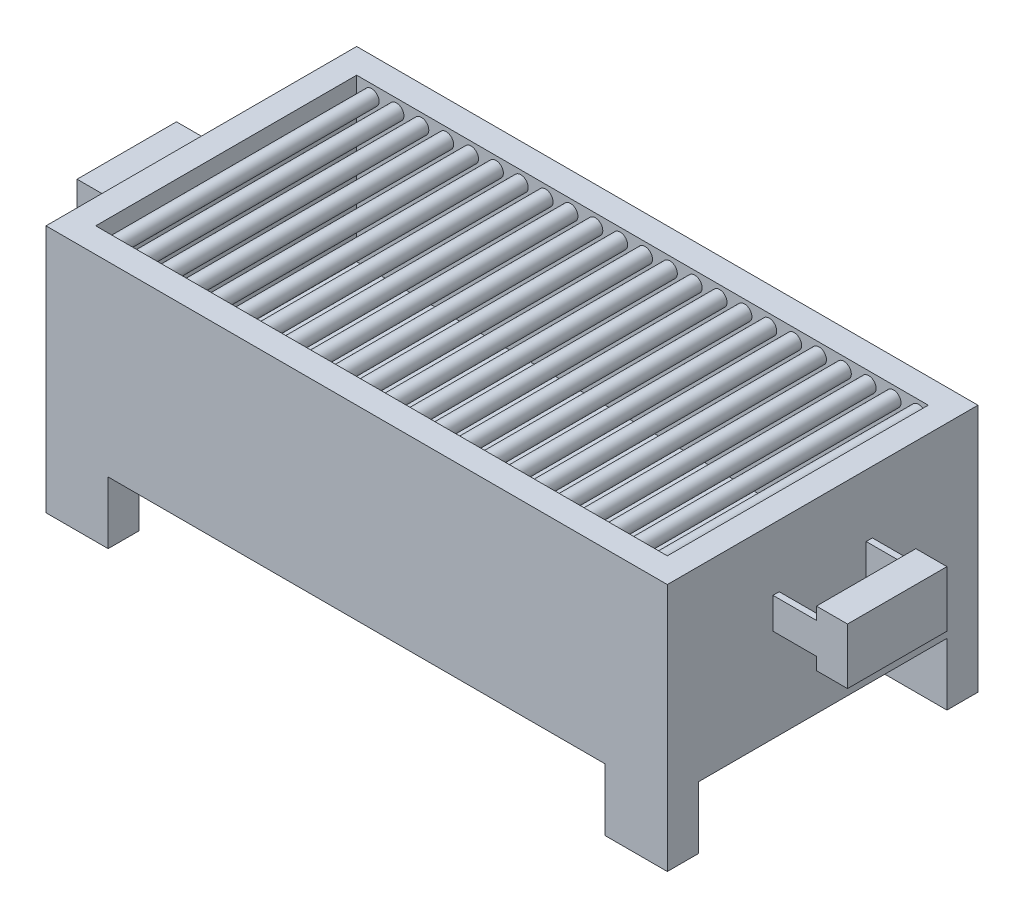
from build123d import *

# Parameters (mm, degrees)
SKETCH1_W           = 50
SKETCH1_H           = 20
BOSS_EXTRUDE1_DEPTH = 12.5
CUT_EXTRUDE1_START  = 20
SKETCH2_W           = 46
SKETCH2_H           = 21
CUT_EXTRUDE1_DEPTH  = 13
BOSS_EXTRUDE2_START = -10.5
SKETCH3_R           = 0.6
BOSS_EXTRUDE2_DEPTH = 21
SKETCH4_W           = 20
SKETCH4_H           = 5
CUT_EXTRUDE2_DEPTH  = 30
SKETCH5_W           = 40
SKETCH5_H           = 5
CUT_EXTRUDE3_DEPTH  = 20
BOSS_EXTRUDE3_DEPTH = 4
CUT_EXTRUDE4_START  = 15
SKETCH7_W           = 3
SKETCH7_H           = 7
CUT_EXTRUDE4_DEPTH  = 8


with BuildPart() as part:
    # Sketch1 → Boss-Extrude1 (new body, symmetric)
    with BuildSketch(Plane.XY):
        with Locations((0, 10)):
            Rectangle(SKETCH1_W, SKETCH1_H)
    extrude(amount=BOSS_EXTRUDE1_DEPTH, both=True)

    # Sketch2 → Cut-Extrude1 (cut)
    with BuildSketch(Plane(origin=(0, 0, 0), x_dir=(1, 0, 0), z_dir=(0, 1, 0)).offset(CUT_EXTRUDE1_START)):
        Rectangle(SKETCH2_W, SKETCH2_H)
    extrude(amount=-CUT_EXTRUDE1_DEPTH, mode=Mode.SUBTRACT)

    # Sketch3 → Boss-Extrude2 (add)
    with BuildSketch(Plane.XY.offset(BOSS_EXTRUDE2_START)):
        with Locations(Location((-21.794964152, 19.065143556, 0), (0, 0, 180))):  # turned: the seam where the file's is
            Circle(SKETCH3_R)
        with Locations(Location((-19.794964152, 19.065143556, 0), (0, 0, 180))):  # turned: the seam where the file's is
            Circle(SKETCH3_R)
        with Locations(Location((-17.794964152, 19.065143556, 0), (0, 0, 180))):  # turned: the seam where the file's is
            Circle(SKETCH3_R)
        with Locations(Location((-15.794964152, 19.065143556, 0), (0, 0, 180))):  # turned: the seam where the file's is
            Circle(SKETCH3_R)
        with Locations(Location((-13.794964152, 19.065143556, 0), (0, 0, 180))):  # turned: the seam where the file's is
            Circle(SKETCH3_R)
        with Locations(Location((-11.794964152, 19.065143556, 0), (0, 0, 180))):  # turned: the seam where the file's is
            Circle(SKETCH3_R)
        with Locations(Location((-9.794964152, 19.065143556, 0), (0, 0, 180))):  # turned: the seam where the file's is
            Circle(SKETCH3_R)
        with Locations(Location((-7.794964152, 19.065143556, 0), (0, 0, 180))):  # turned: the seam where the file's is
            Circle(SKETCH3_R)
        with Locations(Location((-5.794964152, 19.065143556, 0), (0, 0, 180))):  # turned: the seam where the file's is
            Circle(SKETCH3_R)
        with Locations(Location((-3.794964152, 19.065143556, 0), (0, 0, 180))):  # turned: the seam where the file's is
            Circle(SKETCH3_R)
        with Locations(Location((-1.794964152, 19.065143556, 0), (0, 0, 180))):  # turned: the seam where the file's is
            Circle(SKETCH3_R)
        with Locations(Location((0.205035848, 19.065143556, 0), (0, 0, 180))):  # turned: the seam where the file's is
            Circle(SKETCH3_R)
        with Locations(Location((2.205035848, 19.065143556, 0), (0, 0, 180))):  # turned: the seam where the file's is
            Circle(SKETCH3_R)
        with Locations(Location((4.205035848, 19.065143556, 0), (0, 0, 180))):  # turned: the seam where the file's is
            Circle(SKETCH3_R)
        with Locations(Location((6.205035848, 19.065143556, 0), (0, 0, 180))):  # turned: the seam where the file's is
            Circle(SKETCH3_R)
        with Locations(Location((8.205035848, 19.065143556, 0), (0, 0, 180))):  # turned: the seam where the file's is
            Circle(SKETCH3_R)
        with Locations(Location((10.205035848, 19.065143556, 0), (0, 0, 180))):  # turned: the seam where the file's is
            Circle(SKETCH3_R)
        with Locations(Location((12.205035848, 19.065143556, 0), (0, 0, 180))):  # turned: the seam where the file's is
            Circle(SKETCH3_R)
        with Locations(Location((14.205035848, 19.065143556, 0), (0, 0, 180))):  # turned: the seam where the file's is
            Circle(SKETCH3_R)
        with Locations(Location((16.205035848, 19.065143556, 0), (0, 0, 180))):  # turned: the seam where the file's is
            Circle(SKETCH3_R)
        with Locations(Location((18.205035848, 19.065143556, 0), (0, 0, 180))):  # turned: the seam where the file's is
            Circle(SKETCH3_R)
        with Locations(Location((20.205035848, 19.065143556, 0), (0, 0, 180))):  # turned: the seam where the file's is
            Circle(SKETCH3_R)
        with Locations(Location((22.205035848, 19.065143556, 0), (0, 0, 180))):  # turned: the seam where the file's is
            Circle(SKETCH3_R)
    extrude(amount=BOSS_EXTRUDE2_DEPTH)

    # Sketch4 → Cut-Extrude2 (cut, symmetric)
    with BuildSketch(Plane(origin=(0, 0, 0), x_dir=(0, 0, -1), z_dir=(1, 0, 0))):
        with Locations((0, 2.5)):
            Rectangle(SKETCH4_W, SKETCH4_H)
    extrude(amount=CUT_EXTRUDE2_DEPTH, both=True, mode=Mode.SUBTRACT)

    # Sketch5 → Cut-Extrude3 (cut, symmetric)
    with BuildSketch(Plane.XY):
        with Locations((0, 2.5)):
            Rectangle(SKETCH5_W, SKETCH5_H)
    extrude(amount=CUT_EXTRUDE3_DEPTH, both=True, mode=Mode.SUBTRACT)

    # Sketch6 → Boss-Extrude3 (add, symmetric)
    with BuildSketch(Plane.XY):
        Polygon((-25, 15), (-28.5, 15), (-28.5, 16), (-31, 16), (-31, 11.5), (-28.5, 11.5), (-28.5, 12.5), (-25, 12.5), align=None)
        Polygon((25, 15), (28.5, 15), (28.5, 16), (31, 16), (31, 11.5), (28.5, 11.5), (28.5, 12.5), (25, 12.5), align=None)
    extrude(amount=BOSS_EXTRUDE3_DEPTH, both=True)

    # Sketch7 → Cut-Extrude4 (cut)
    with BuildSketch(Plane(origin=(0, 0, 0), x_dir=(1, 0, 0), z_dir=(0, 1, 0)).offset(CUT_EXTRUDE4_START)):
        with Locations((-26.5, 0)):
            Rectangle(SKETCH7_W, SKETCH7_H)
        with Locations((26.5, 0)):
            Rectangle(SKETCH7_W, SKETCH7_H)
    extrude(amount=-CUT_EXTRUDE4_DEPTH, mode=Mode.SUBTRACT)


solid = part.part
